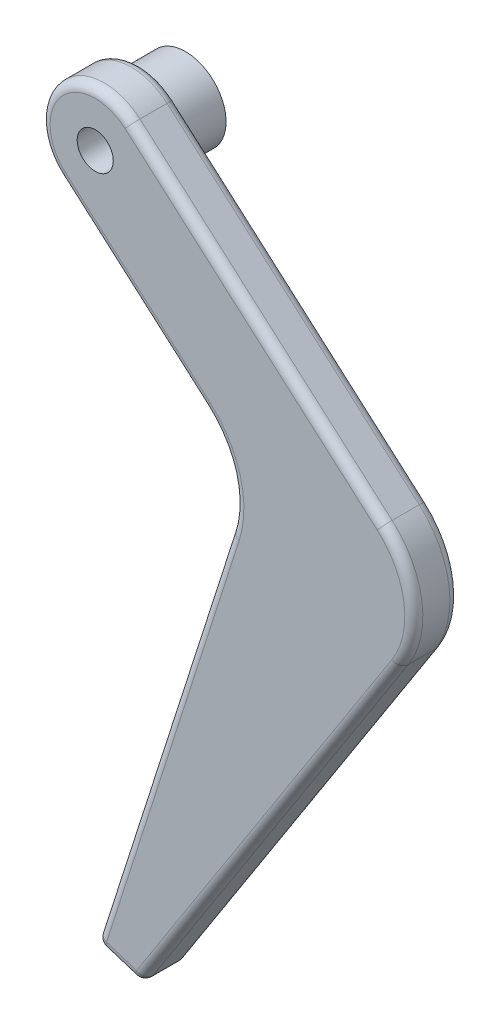
from build123d import *

# Parameters (mm, degrees)
SKETCH2_R           = 2
BOSS_EXTRUDE1_DEPTH = 2.5
FILLET1_R           = 1
SKETCH3_R           = 4.5
BOSS_EXTRUDE2_DEPTH = 5
SKETCH4_R           = 2.5
CUT_EXTRUDE1_DEPTH  = 3
SKETCH5_R           = 1
CUT_EXTRUDE2_DEPTH  = 5


with BuildPart() as part:
    # Sketch2 → Boss-Extrude1 (new body, symmetric)
    with BuildSketch(Plane.XY):
        with BuildLine():
            Line((-10, -126), (-5, -127.601468854))
            Line((-5, -127.601468854), (23.717421377, -82.972253802))
            ThreePointArc((23.717421377, -82.972253802), (25.211420403, -76.174808821), (21.908456188, -70.048821656))
            Line((21.908456188, -70.048821656), (-6.039708144, -45.492662824))
            ThreePointArc((-6.039708144, -45.492662824), (-14.507337176, -46.039708144), (-13.960291856, -54.507337176))
            Line((-13.960291856, -54.507337176), (2.078857085, -68.599850882))
            ThreePointArc((2.078857085, -68.599850882), (5.116155087, -73.445037833), (5.001799686, -79.162374502))
            Line((5.001799686, -79.162374502), (-10, -126))
        make_face()
        with Locations((-10, -50)):
            Circle(SKETCH2_R, mode=Mode.SUBTRACT)
    extrude(amount=BOSS_EXTRUDE1_DEPTH, both=True)

    # Fillet1
    fillet1_edges = [part.edges().sort_by_distance(p)[0] for p in [
        (25.211420403, -76.174808821, -2.5),
        (9.358710688, -105.286861328, -2.5),
        (-7.5, -126.800734427, -2.5),
        (-2.499100157, -102.581187251, -2.5),
        (9.358710688, -105.286861328, 2.5),
        (-5, -127.601468854, 0),
        (-10, -126, 0),
        (25.211420403, -76.174808821, 2.5),
        (7.934374022, -57.77074224, 2.5),
        (-14.507337176, -46.039708144, 2.5),
        (-5.940717386, -61.553594029, 2.5),
        (5.116155087, -73.445037833, 2.5),
        (-2.499100157, -102.581187251, 2.5),
        (5.116155087, -73.445037833, -2.5),
        (-7.5, -126.800734427, 2.5),
        (-5.940717386, -61.553594029, -2.5),
        (-14.507337176, -46.039708144, -2.5),
        (7.934374022, -57.77074224, -2.5),
    ]]
    fillet(fillet1_edges, radius=FILLET1_R)

    # Sketch3 → Boss-Extrude2 (add)
    with BuildSketch(Plane(origin=(0, 0, -2.5), x_dir=(-1, 0, 0), z_dir=(0, 0, -1))):
        with Locations((10, -50)):
            Circle(SKETCH3_R)
    extrude(amount=BOSS_EXTRUDE2_DEPTH)

    # Sketch4 → Cut-Extrude1 (cut)
    with BuildSketch(Plane(origin=(0, 0, -7.5), x_dir=(-1, 0, 0), z_dir=(0, 0, -1))):
        with Locations((10, -50)):
            Circle(SKETCH4_R)
    extrude(amount=-CUT_EXTRUDE1_DEPTH, mode=Mode.SUBTRACT)

    # Sketch5 → Cut-Extrude2 (cut)
    with BuildSketch(Plane.XY.offset(-2.5)):
        with Locations((-10, -50)):
            Circle(SKETCH5_R)
    extrude(amount=-CUT_EXTRUDE2_DEPTH, mode=Mode.SUBTRACT)


solid = part.part
